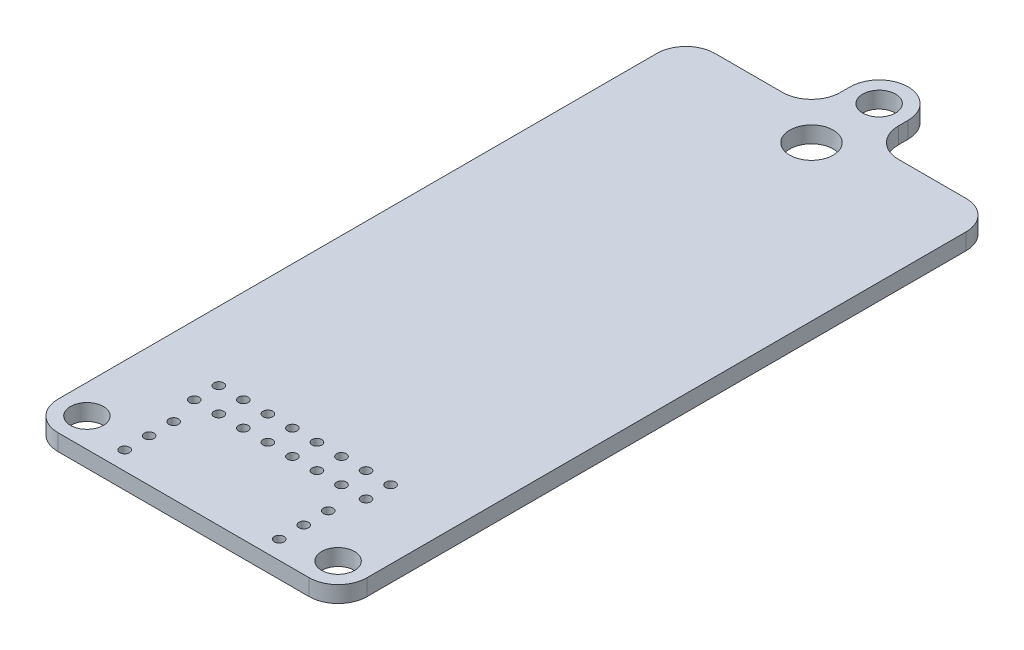
from build123d import *

# Parameters (mm, degrees)
SKETCH1_R           = 1.7
SKETCH1_R_2         = 2.25
BOSS_EXTRUDE1_DEPTH = 1.7
CUT_EXTRUDE1_REACH  = 3.7
SKETCH2_R           = 0.5


with BuildPart() as part:
    # Sketch1 → Boss-Extrude1 (new body)
    with BuildSketch(Plane(origin=(0, 0, 0), x_dir=(1, 0, 0), z_dir=(0, 1, 0))):
        with BuildLine():
            Line((3, 68), (10, 68))
            ThreePointArc((10, 68), (12.121320344, 68.878679656), (13, 71))
            Line((13, 71), (13, 72))
            ThreePointArc((13, 72), (16, 75), (19, 72))
            Line((19, 72), (19, 71))
            ThreePointArc((19, 71), (19.878679656, 68.878679656), (22, 68))
            Line((22, 68), (29, 68))
            ThreePointArc((29, 68), (31.121320344, 67.121320344), (32, 65))
            Line((32, 65), (32, 3))
            ThreePointArc((32, 3), (31.121320344, 0.878679656), (29, 0))
            Line((29, 0), (3, 0))
            ThreePointArc((3, 0), (0.878679656, 0.878679656), (0, 3))
            Line((0, 3), (0, 65))
            ThreePointArc((0, 65), (0.878679656, 67.121320344), (3, 68))
        make_face()
        with Locations((16, 72)):
            Circle(SKETCH1_R, mode=Mode.SUBTRACT)
        with Locations((29, 3)):
            Circle(SKETCH1_R, mode=Mode.SUBTRACT)
        with Locations((3, 3)):
            Circle(SKETCH1_R, mode=Mode.SUBTRACT)
        with Locations((16, 65)):
            Circle(SKETCH1_R_2, mode=Mode.SUBTRACT)
    extrude(amount=BOSS_EXTRUDE1_DEPTH)

    # Sketch2 → Cut-Extrude1 (cut, up to next)
    with BuildSketch(Plane(origin=(0, 1.7, 0), x_dir=(1, 0, 0), z_dir=(0, 1, 0)), mode=Mode.PRIVATE) as cut_extrude1_sk1:
        with Locations((8, 1.9)):
            Circle(SKETCH2_R)
    cut_extrude1_tool1 = extrude(cut_extrude1_sk1.sketch, amount=-CUT_EXTRUDE1_REACH, mode=Mode.PRIVATE) & part.part
    add(cut_extrude1_tool1.solids().sort_by_distance((8, 1.7, -1.9))[0], mode=Mode.SUBTRACT)
    # Sketch2 → Cut-Extrude1 (cut, up to next)
    with BuildSketch(Plane(origin=(0, 1.7, 0), x_dir=(1, 0, 0), z_dir=(0, 1, 0)), mode=Mode.PRIVATE) as cut_extrude1_sk2:
        with Locations((8, 4.44)):
            Circle(SKETCH2_R)
    cut_extrude1_tool2 = extrude(cut_extrude1_sk2.sketch, amount=-CUT_EXTRUDE1_REACH, mode=Mode.PRIVATE) & part.part
    add(cut_extrude1_tool2.solids().sort_by_distance((8, 1.7, -4.44))[0], mode=Mode.SUBTRACT)
    # Sketch2 → Cut-Extrude1 (cut, up to next)
    with BuildSketch(Plane(origin=(0, 1.7, 0), x_dir=(1, 0, 0), z_dir=(0, 1, 0)), mode=Mode.PRIVATE) as cut_extrude1_sk3:
        with Locations((8, 6.98)):
            Circle(SKETCH2_R)
    cut_extrude1_tool3 = extrude(cut_extrude1_sk3.sketch, amount=-CUT_EXTRUDE1_REACH, mode=Mode.PRIVATE) & part.part
    add(cut_extrude1_tool3.solids().sort_by_distance((8, 1.7, -6.98))[0], mode=Mode.SUBTRACT)
    # Sketch2 → Cut-Extrude1 (cut, up to next)
    with BuildSketch(Plane(origin=(0, 1.7, 0), x_dir=(1, 0, 0), z_dir=(0, 1, 0)), mode=Mode.PRIVATE) as cut_extrude1_sk4:
        with Locations((24, 6.98)):
            Circle(SKETCH2_R)
    cut_extrude1_tool4 = extrude(cut_extrude1_sk4.sketch, amount=-CUT_EXTRUDE1_REACH, mode=Mode.PRIVATE) & part.part
    add(cut_extrude1_tool4.solids().sort_by_distance((24, 1.7, -6.98))[0], mode=Mode.SUBTRACT)
    # Sketch2 → Cut-Extrude1 (cut, up to next)
    with BuildSketch(Plane(origin=(0, 1.7, 0), x_dir=(1, 0, 0), z_dir=(0, 1, 0)), mode=Mode.PRIVATE) as cut_extrude1_sk5:
        with Locations((24, 4.44)):
            Circle(SKETCH2_R)
    cut_extrude1_tool5 = extrude(cut_extrude1_sk5.sketch, amount=-CUT_EXTRUDE1_REACH, mode=Mode.PRIVATE) & part.part
    add(cut_extrude1_tool5.solids().sort_by_distance((24, 1.7, -4.44))[0], mode=Mode.SUBTRACT)
    # Sketch2 → Cut-Extrude1 (cut, up to next)
    with BuildSketch(Plane(origin=(0, 1.7, 0), x_dir=(1, 0, 0), z_dir=(0, 1, 0)), mode=Mode.PRIVATE) as cut_extrude1_sk6:
        with Locations((24, 1.9)):
            Circle(SKETCH2_R)
    cut_extrude1_tool6 = extrude(cut_extrude1_sk6.sketch, amount=-CUT_EXTRUDE1_REACH, mode=Mode.PRIVATE) & part.part
    add(cut_extrude1_tool6.solids().sort_by_distance((24, 1.7, -1.9))[0], mode=Mode.SUBTRACT)
    # Sketch2 → Cut-Extrude1 (cut, up to next)
    with BuildSketch(Plane(origin=(0, 1.7, 0), x_dir=(1, 0, 0), z_dir=(0, 1, 0)), mode=Mode.PRIVATE) as cut_extrude1_sk7:
        with Locations((7.11, 10)):
            Circle(SKETCH2_R)
    cut_extrude1_tool7 = extrude(cut_extrude1_sk7.sketch, amount=-CUT_EXTRUDE1_REACH, mode=Mode.PRIVATE) & part.part
    add(cut_extrude1_tool7.solids().sort_by_distance((7.11, 1.7, -10))[0], mode=Mode.SUBTRACT)
    # Sketch2 → Cut-Extrude1 (cut, up to next)
    with BuildSketch(Plane(origin=(0, 1.7, 0), x_dir=(1, 0, 0), z_dir=(0, 1, 0)), mode=Mode.PRIVATE) as cut_extrude1_sk8:
        with Locations((9.65, 10)):
            Circle(SKETCH2_R)
    cut_extrude1_tool8 = extrude(cut_extrude1_sk8.sketch, amount=-CUT_EXTRUDE1_REACH, mode=Mode.PRIVATE) & part.part
    add(cut_extrude1_tool8.solids().sort_by_distance((9.65, 1.7, -10))[0], mode=Mode.SUBTRACT)
    # Sketch2 → Cut-Extrude1 (cut, up to next)
    with BuildSketch(Plane(origin=(0, 1.7, 0), x_dir=(1, 0, 0), z_dir=(0, 1, 0)), mode=Mode.PRIVATE) as cut_extrude1_sk9:
        with Locations((12.19, 10)):
            Circle(SKETCH2_R)
    cut_extrude1_tool9 = extrude(cut_extrude1_sk9.sketch, amount=-CUT_EXTRUDE1_REACH, mode=Mode.PRIVATE) & part.part
    add(cut_extrude1_tool9.solids().sort_by_distance((12.19, 1.7, -10))[0], mode=Mode.SUBTRACT)
    # Sketch2 → Cut-Extrude1 (cut, up to next)
    with BuildSketch(Plane(origin=(0, 1.7, 0), x_dir=(1, 0, 0), z_dir=(0, 1, 0)), mode=Mode.PRIVATE) as cut_extrude1_sk10:
        with Locations((14.73, 10)):
            Circle(SKETCH2_R)
    cut_extrude1_tool10 = extrude(cut_extrude1_sk10.sketch, amount=-CUT_EXTRUDE1_REACH, mode=Mode.PRIVATE) & part.part
    add(cut_extrude1_tool10.solids().sort_by_distance((14.73, 1.7, -10))[0], mode=Mode.SUBTRACT)
    # Sketch2 → Cut-Extrude1 (cut, up to next)
    with BuildSketch(Plane(origin=(0, 1.7, 0), x_dir=(1, 0, 0), z_dir=(0, 1, 0)), mode=Mode.PRIVATE) as cut_extrude1_sk11:
        with Locations((17.27, 10)):
            Circle(SKETCH2_R)
    cut_extrude1_tool11 = extrude(cut_extrude1_sk11.sketch, amount=-CUT_EXTRUDE1_REACH, mode=Mode.PRIVATE) & part.part
    add(cut_extrude1_tool11.solids().sort_by_distance((17.27, 1.7, -10))[0], mode=Mode.SUBTRACT)
    # Sketch2 → Cut-Extrude1 (cut, up to next)
    with BuildSketch(Plane(origin=(0, 1.7, 0), x_dir=(1, 0, 0), z_dir=(0, 1, 0)), mode=Mode.PRIVATE) as cut_extrude1_sk12:
        with Locations((19.81, 10)):
            Circle(SKETCH2_R)
    cut_extrude1_tool12 = extrude(cut_extrude1_sk12.sketch, amount=-CUT_EXTRUDE1_REACH, mode=Mode.PRIVATE) & part.part
    add(cut_extrude1_tool12.solids().sort_by_distance((19.81, 1.7, -10))[0], mode=Mode.SUBTRACT)
    # Sketch2 → Cut-Extrude1 (cut, up to next)
    with BuildSketch(Plane(origin=(0, 1.7, 0), x_dir=(1, 0, 0), z_dir=(0, 1, 0)), mode=Mode.PRIVATE) as cut_extrude1_sk13:
        with Locations((22.35, 10)):
            Circle(SKETCH2_R)
    cut_extrude1_tool13 = extrude(cut_extrude1_sk13.sketch, amount=-CUT_EXTRUDE1_REACH, mode=Mode.PRIVATE) & part.part
    add(cut_extrude1_tool13.solids().sort_by_distance((22.35, 1.7, -10))[0], mode=Mode.SUBTRACT)
    # Sketch2 → Cut-Extrude1 (cut, up to next)
    with BuildSketch(Plane(origin=(0, 1.7, 0), x_dir=(1, 0, 0), z_dir=(0, 1, 0)), mode=Mode.PRIVATE) as cut_extrude1_sk14:
        with Locations((24.89, 10)):
            Circle(SKETCH2_R)
    cut_extrude1_tool14 = extrude(cut_extrude1_sk14.sketch, amount=-CUT_EXTRUDE1_REACH, mode=Mode.PRIVATE) & part.part
    add(cut_extrude1_tool14.solids().sort_by_distance((24.89, 1.7, -10))[0], mode=Mode.SUBTRACT)
    # Sketch2 → Cut-Extrude1 (cut, up to next)
    with BuildSketch(Plane(origin=(0, 1.7, 0), x_dir=(1, 0, 0), z_dir=(0, 1, 0)), mode=Mode.PRIVATE) as cut_extrude1_sk15:
        with Locations((9.65, 12.54)):
            Circle(SKETCH2_R)
    cut_extrude1_tool15 = extrude(cut_extrude1_sk15.sketch, amount=-CUT_EXTRUDE1_REACH, mode=Mode.PRIVATE) & part.part
    add(cut_extrude1_tool15.solids().sort_by_distance((9.65, 1.7, -12.54))[0], mode=Mode.SUBTRACT)
    # Sketch2 → Cut-Extrude1 (cut, up to next)
    with BuildSketch(Plane(origin=(0, 1.7, 0), x_dir=(1, 0, 0), z_dir=(0, 1, 0)), mode=Mode.PRIVATE) as cut_extrude1_sk16:
        with Locations((12.19, 12.54)):
            Circle(SKETCH2_R)
    cut_extrude1_tool16 = extrude(cut_extrude1_sk16.sketch, amount=-CUT_EXTRUDE1_REACH, mode=Mode.PRIVATE) & part.part
    add(cut_extrude1_tool16.solids().sort_by_distance((12.19, 1.7, -12.54))[0], mode=Mode.SUBTRACT)
    # Sketch2 → Cut-Extrude1 (cut, up to next)
    with BuildSketch(Plane(origin=(0, 1.7, 0), x_dir=(1, 0, 0), z_dir=(0, 1, 0)), mode=Mode.PRIVATE) as cut_extrude1_sk17:
        with Locations((14.73, 12.54)):
            Circle(SKETCH2_R)
    cut_extrude1_tool17 = extrude(cut_extrude1_sk17.sketch, amount=-CUT_EXTRUDE1_REACH, mode=Mode.PRIVATE) & part.part
    add(cut_extrude1_tool17.solids().sort_by_distance((14.73, 1.7, -12.54))[0], mode=Mode.SUBTRACT)
    # Sketch2 → Cut-Extrude1 (cut, up to next)
    with BuildSketch(Plane(origin=(0, 1.7, 0), x_dir=(1, 0, 0), z_dir=(0, 1, 0)), mode=Mode.PRIVATE) as cut_extrude1_sk18:
        with Locations((17.27, 12.54)):
            Circle(SKETCH2_R)
    cut_extrude1_tool18 = extrude(cut_extrude1_sk18.sketch, amount=-CUT_EXTRUDE1_REACH, mode=Mode.PRIVATE) & part.part
    add(cut_extrude1_tool18.solids().sort_by_distance((17.27, 1.7, -12.54))[0], mode=Mode.SUBTRACT)
    # Sketch2 → Cut-Extrude1 (cut, up to next)
    with BuildSketch(Plane(origin=(0, 1.7, 0), x_dir=(1, 0, 0), z_dir=(0, 1, 0)), mode=Mode.PRIVATE) as cut_extrude1_sk19:
        with Locations((19.81, 12.54)):
            Circle(SKETCH2_R)
    cut_extrude1_tool19 = extrude(cut_extrude1_sk19.sketch, amount=-CUT_EXTRUDE1_REACH, mode=Mode.PRIVATE) & part.part
    add(cut_extrude1_tool19.solids().sort_by_distance((19.81, 1.7, -12.54))[0], mode=Mode.SUBTRACT)
    # Sketch2 → Cut-Extrude1 (cut, up to next)
    with BuildSketch(Plane(origin=(0, 1.7, 0), x_dir=(1, 0, 0), z_dir=(0, 1, 0)), mode=Mode.PRIVATE) as cut_extrude1_sk20:
        with Locations((22.35, 12.54)):
            Circle(SKETCH2_R)
    cut_extrude1_tool20 = extrude(cut_extrude1_sk20.sketch, amount=-CUT_EXTRUDE1_REACH, mode=Mode.PRIVATE) & part.part
    add(cut_extrude1_tool20.solids().sort_by_distance((22.35, 1.7, -12.54))[0], mode=Mode.SUBTRACT)
    # Sketch2 → Cut-Extrude1 (cut, up to next)
    with BuildSketch(Plane(origin=(0, 1.7, 0), x_dir=(1, 0, 0), z_dir=(0, 1, 0)), mode=Mode.PRIVATE) as cut_extrude1_sk21:
        with Locations((24.89, 12.54)):
            Circle(SKETCH2_R)
    cut_extrude1_tool21 = extrude(cut_extrude1_sk21.sketch, amount=-CUT_EXTRUDE1_REACH, mode=Mode.PRIVATE) & part.part
    add(cut_extrude1_tool21.solids().sort_by_distance((24.89, 1.7, -12.54))[0], mode=Mode.SUBTRACT)
    # Sketch2 → Cut-Extrude1 (cut, up to next)
    with BuildSketch(Plane(origin=(0, 1.7, 0), x_dir=(1, 0, 0), z_dir=(0, 1, 0)), mode=Mode.PRIVATE) as cut_extrude1_sk22:
        with Locations((7.11, 12.54)):
            Circle(SKETCH2_R)
    cut_extrude1_tool22 = extrude(cut_extrude1_sk22.sketch, amount=-CUT_EXTRUDE1_REACH, mode=Mode.PRIVATE) & part.part
    add(cut_extrude1_tool22.solids().sort_by_distance((7.11, 1.7, -12.54))[0], mode=Mode.SUBTRACT)


solid = part.part
